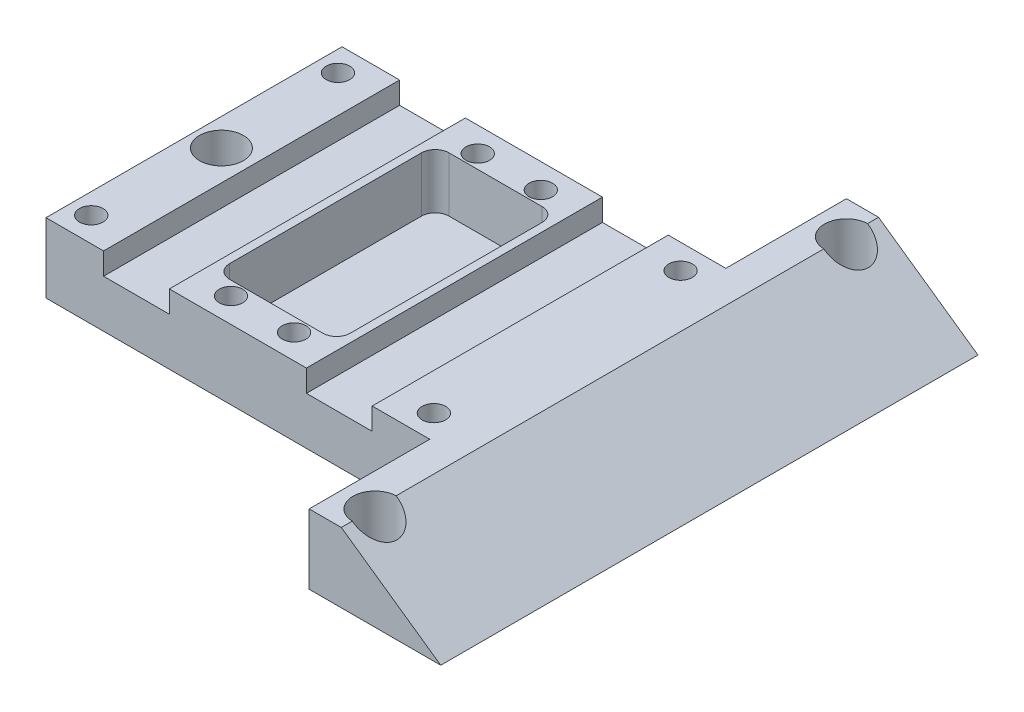
from build123d import *

# Parameters (mm, degrees)
RESSALTO_EXTRUS_O1_DEPTH                            = 98
ESBO_O4_W                                           = 33
ESBO_O4_H                                           = 22
CORTE_EXTRUS_O3_DEPTH                               = 25
ESBO_O2_R                                           = 4
CORTE_EXTRUS_O1_DEPTH                               = 98
ESBO_O10_W                                          = 12
ESBO_O10_H                                          = 4
CORTE_EXTRUS_O8_DEPTH                               = 77
ESBO_O11_R                                          = 1.6
CORTE_EXTRUS_O9_DEPTH                               = 20
ESBO_O12_W                                          = 22
ESBO_O12_H                                          = 40
CORTE_EXTRUS_O10_DEPTH                              = 10
FILETE1_R                                           = 2.5
ESCAREADO_PARA_PARAFUSO_ALLEN_SEXTAVADO_D           = 4.3
ESCAREADO_PARA_PARAFUSO_ALLEN_SEXTAVADO_CSINK_D     = 8.96
ESCAREADO_PARA_PARAFUSO_ALLEN_SEXTAVADO_CSINK_ANGLE = 90
ESBO_O15_W                                          = 4
ESBO_O15_H                                          = 22
CORTE_EXTRUS_O11_DEPTH                              = 13.7


with BuildPart() as part:
    # Esboço1 → Ressalto-extrusão1 (new body)
    with BuildSketch(Plane.XY):
        Polygon((0, 0), (94, 0), (75.862520314, 12.7), (0, 12.7), align=None)
    extrude(amount=RESSALTO_EXTRUS_O1_DEPTH)

    # Esboço4 → Corte-extrusão3 (cut)
    with BuildSketch(Plane(origin=(0, 12.7, 0), x_dir=(1, 0, 0), z_dir=(0, 1, 0))):
        with Locations((16.5, -87)):
            Rectangle(ESBO_O4_W, ESBO_O4_H)
        with Locations((16.5, -11)):
            Rectangle(ESBO_O4_W, ESBO_O4_H)
        with Locations((53.5, -87)):
            Rectangle(ESBO_O4_W, ESBO_O4_H)
        with Locations((53.5, -11)):
            Rectangle(ESBO_O4_W, ESBO_O4_H)
    extrude(amount=-CORTE_EXTRUS_O3_DEPTH, mode=Mode.SUBTRACT)

    # Esboço2 → Corte-extrusão1 (cut)
    with BuildSketch(Plane(origin=(0, 12.7, 0), x_dir=(1, 0, 0), z_dir=(0, 1, 0))):
        with Locations((76, -92)):
            Circle(ESBO_O2_R)
        with Locations((76, -6)):
            Circle(ESBO_O2_R)
        with Locations((5, -49)):
            Circle(ESBO_O2_R)
    extrude(amount=-CORTE_EXTRUS_O1_DEPTH, mode=Mode.SUBTRACT)

    # Esboço10 → Corte-extrusão8 (cut, through all)
    with BuildSketch(Plane.XY.offset(76)):
        with Locations((16.5, 10.7)):
            Rectangle(ESBO_O10_W, ESBO_O10_H)
        with Locations((53.5, 10.7)):
            Rectangle(ESBO_O10_W, ESBO_O10_H)
    extrude(amount=-CORTE_EXTRUS_O8_DEPTH, mode=Mode.SUBTRACT)

    # Esboço11 → Corte-extrusão9 (cut)
    with BuildSketch(Plane(origin=(0, 12.7, 0), x_dir=(1, 0, 0), z_dir=(0, 1, 0))):
        with Locations((29.25, -26.5)):
            Circle(ESBO_O11_R)
        with Locations((29.25, -71.5)):
            Circle(ESBO_O11_R)
        with Locations((3.75, -71.5)):
            Circle(ESBO_O11_R)
        with Locations((3.75, -26.5)):
            Circle(ESBO_O11_R)
        with Locations((40.75, -26.5)):
            Circle(ESBO_O11_R)
        with Locations((66.25, -26.5)):
            Circle(ESBO_O11_R)
        with Locations((66.25, -71.5)):
            Circle(ESBO_O11_R)
        with Locations((40.75, -71.5)):
            Circle(ESBO_O11_R)
    extrude(amount=-CORTE_EXTRUS_O9_DEPTH, mode=Mode.SUBTRACT)

    # Esboço12 → Corte-extrusão10 (cut)
    with BuildSketch(Plane(origin=(0, 12.7, 0), x_dir=(1, 0, 0), z_dir=(0, 1, 0))):
        with Locations((35, -49)):
            Rectangle(ESBO_O12_W, ESBO_O12_H)
    extrude(amount=-CORTE_EXTRUS_O10_DEPTH, mode=Mode.SUBTRACT)

    # Filete1
    filete1_edges = [part.edges().sort_by_distance(p)[0] for p in [
        (46, 7.7, 29),
        (46, 7.7, 69),
        (24, 7.7, 69),
        (24, 7.7, 29),
    ]]
    fillet(filete1_edges, radius=FILETE1_R)

    # Escareado para parafuso Allen sextavado escareado de M41 (through all)
    with Locations(Plane(origin=(0, 0, 0), x_dir=(-1, 0, 0), z_dir=(0, -1, 0))):
        with Locations((-66.25, -71.5), (-66.25, -26.5), (-40.75, -26.5), (-29.25, -26.5), (-29.25, -71.5), (-40.75, -71.5), (-3.75, -71.5), (-3.75, -26.5)):
            CounterSinkHole(ESCAREADO_PARA_PARAFUSO_ALLEN_SEXTAVADO_D / 2, ESCAREADO_PARA_PARAFUSO_ALLEN_SEXTAVADO_CSINK_D / 2, counter_sink_angle=ESCAREADO_PARA_PARAFUSO_ALLEN_SEXTAVADO_CSINK_ANGLE)

    # Esboço15 → Corte-extrusão11 (cut, through all)
    with BuildSketch(Plane(origin=(0, 12.7, 0), x_dir=(1, 0, 0), z_dir=(0, 1, 0))):
        with Locations((35, -11)):
            Rectangle(ESBO_O15_W, ESBO_O15_H)
        with Locations((35, -87)):
            Rectangle(ESBO_O15_W, ESBO_O15_H)
    extrude(amount=-CORTE_EXTRUS_O11_DEPTH, mode=Mode.SUBTRACT)


solid = part.part
